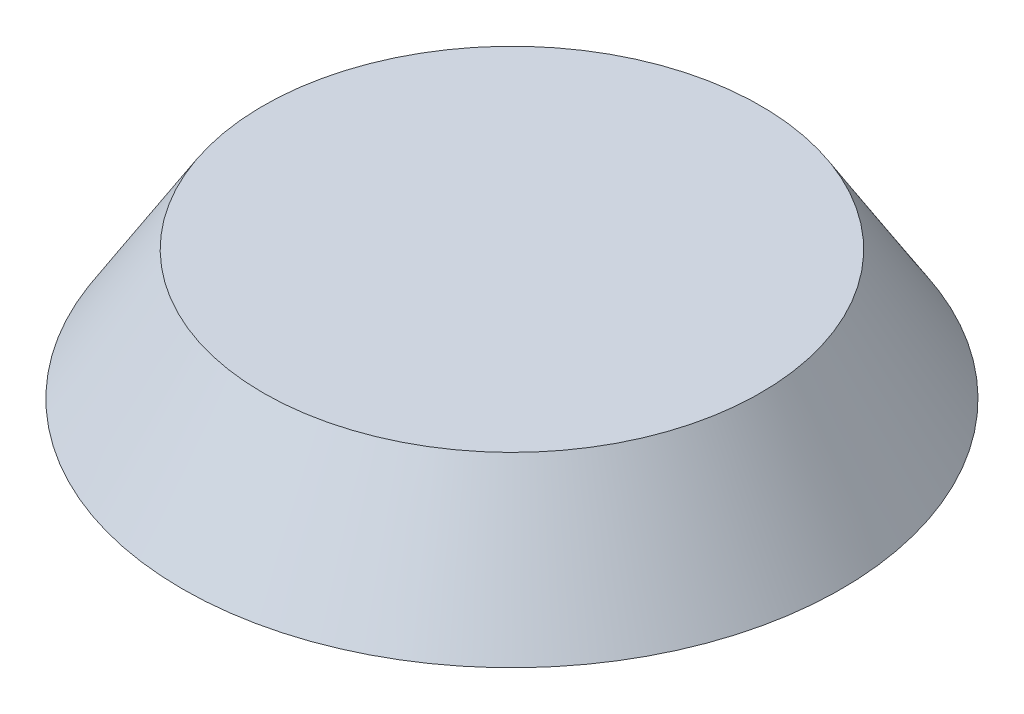
from build123d import *

# Parameters (mm, degrees)
IZIM2_R                     = 5.095961834
IZIM2_R_2                   = 2.44
Y_KSEKLIK_EKSTR_ZYON1_DEPTH = 2
Y_KSEKLIK_EKSTR_ZYON1_TAPER = 32
IZIM3_R                     = 3.44
IZIM3_R_2                   = 2.44
EKSTR_ZYON_NCE1_DEPTH       = 2
IZIM4_R                     = 3.84622313
Y_KSEKLIK_EKSTR_ZYON2_DEPTH = 0.2
IZIM5_R                     = 2.44
IZIM5_R_2                   = 1.22
EKSTR_ZYON_NCE2_DEPTH       = 1.8


with BuildPart() as part:
    # Çizim2 → Yükseklik-Ekstrüzyon1 (new body)
    with BuildSketch(Plane(origin=(0, 0, 0), x_dir=(1, 0, 0), z_dir=(0, 1, 0))):
        Circle(IZIM2_R)
        Circle(IZIM2_R_2, mode=Mode.SUBTRACT)
    extrude(amount=Y_KSEKLIK_EKSTR_ZYON1_DEPTH, taper=Y_KSEKLIK_EKSTR_ZYON1_TAPER)

    # Çizim3 → Ekstrüzyon-İnce1 (add)
    with BuildSketch(Plane(origin=(0, 0, 0), x_dir=(1, 0, 0), z_dir=(0, 1, 0))):
        Circle(IZIM3_R)
        Circle(IZIM3_R_2, mode=Mode.SUBTRACT)
    extrude(amount=EKSTR_ZYON_NCE1_DEPTH)

    # Çizim4 → Yükseklik-Ekstrüzyon2 (add)
    with BuildSketch(Plane(origin=(0, 2, 0), x_dir=(1, 0, 0), z_dir=(0, 1, 0))):
        Circle(IZIM4_R)
    extrude(amount=-Y_KSEKLIK_EKSTR_ZYON2_DEPTH)

    # Çizim5 → Ekstrüzyon-İnce2 (add)
    with BuildSketch(Plane(origin=(0, 0, 0), x_dir=(1, 0, 0), z_dir=(0, 1, 0))):
        Circle(IZIM5_R)
        Circle(IZIM5_R_2, mode=Mode.SUBTRACT)
    extrude(amount=EKSTR_ZYON_NCE2_DEPTH)


solid = part.part
